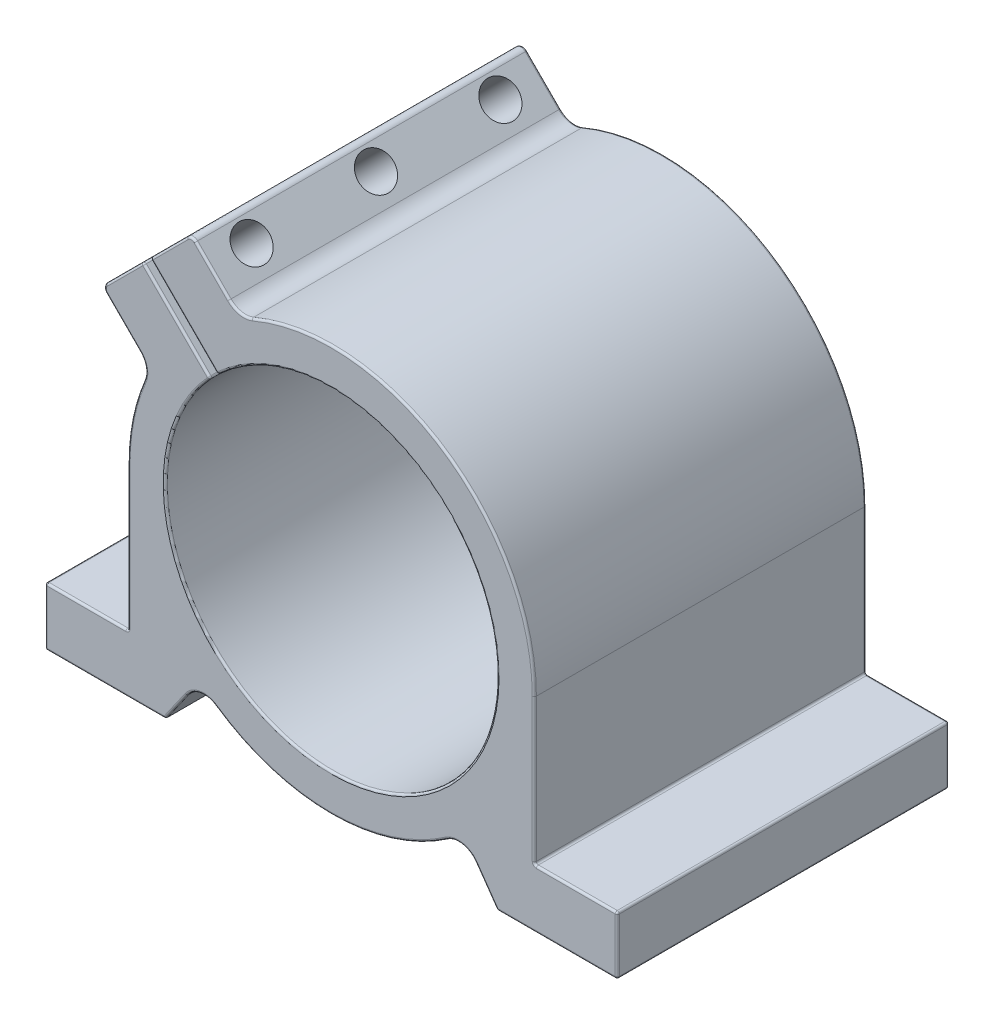
from build123d import *

# Parameters (mm, degrees)
EXTRUDE_1_DEPTH     = 40
FILLET_1_R          = 5
SKETCH_2_R          = 4.25
CUT_EXTRUDE_1_DEPTH = 16.5
SKETCH_3_R          = 3.1
CUT_EXTRUDE_2_DEPTH = 80
FILLET_2_R          = 1.5
FILLET_3_R          = 0.5


with BuildPart() as part:
    # Эскиз1 → Бобышка-Вытянуть1 (new body, symmetric)
    with BuildSketch(Plane.XY):
        with BuildLine():
            Line((-69, -49), (-40, -49))
            Line((-40, -49), (-31.795747001, -37.283112433))
            ThreePointArc((-31.795747001, -37.283112433), (-44.491525053, -20.530567417), (-49, 0))
            Line((-49, 0), (-49, -35))
            Line((-49, -35), (-69, -35))
            Line((-69, -35), (-69, -49))
        make_face()
        with BuildLine():
            ThreePointArc((-31.795747001, -37.283112433), (-16.942955681, -45.977562493), (-1.13e-07, -49))
            ThreePointArc((-1.13e-07, -49), (16.942955575, -45.977562532), (31.795747001, -37.283112433))
            ThreePointArc((31.795747001, -37.283112433), (44.491525053, -20.530567417), (49, 0))
            ThreePointArc((49, 0), (25.650917751, 41.749615789), (-22.144098715, 43.710855541))
            Line((-22.144098715, 43.710855541), (-15.364637764, 36.93139459))
            ThreePointArc((-15.364637764, 36.93139459), (22.197009815, 33.276008704), (40, 0))
            ThreePointArc((40, 0), (-7.834035243, -39.225347568), (-36.93139459, 15.364637764))
            Line((-36.93139459, 15.364637764), (-43.710855541, 22.144098715))
            ThreePointArc((-43.710855541, 22.144098715), (-47.659374322, 11.38349855), (-49, 0))
            ThreePointArc((-49, 0), (-44.491525053, -20.530567417), (-31.795747001, -37.283112433))
        make_face()
        with BuildLine():
            Line((40, -49), (69, -49))
            Line((69, -49), (69, -35))
            Line((69, -35), (49, -35))
            Line((49, -35), (49, 0))
            ThreePointArc((49, 0), (44.491525053, -20.530567417), (31.795747001, -37.283112433))
            Line((31.795747001, -37.283112433), (40, -49))
        make_face()
        with BuildLine():
            Line((-55.317291575, 33.750534749), (-43.710855541, 22.144098715))
            ThreePointArc((-43.710855541, 22.144098715), (-40.038824422, 28.246991679), (-35.520839896, 33.753072943))
            Line((-35.520839896, 33.753072943), (-45.417796639, 43.650029686))
            Line((-45.417796639, 43.650029686), (-55.317291575, 33.750534749))
        make_face()
        with BuildLine():
            ThreePointArc((-33.753072943, 35.520839896), (-28.246991679, 40.038824422), (-22.144098715, 43.710855541))
            Line((-22.144098715, 43.710855541), (-33.750534749, 55.317291575))
            Line((-33.750534749, 55.317291575), (-43.650029686, 45.417796639))
            Line((-43.650029686, 45.417796639), (-33.753072943, 35.520839896))
        make_face()
        with BuildLine():
            ThreePointArc((-35.520839896, 33.753072943), (-40.038824422, 28.246991679), (-43.710855541, 22.144098715))
            Line((-43.710855541, 22.144098715), (-36.93139459, 15.364637764))
            ThreePointArc((-36.93139459, 15.364637764), (-33.585157991, 21.726416242), (-29.154340671, 27.386573718))
            Line((-29.154340671, 27.386573718), (-35.520839896, 33.753072943))
        make_face()
        with BuildLine():
            Line((-15.364637764, 36.93139459), (-22.144098715, 43.710855541))
            ThreePointArc((-22.144098715, 43.710855541), (-28.246991679, 40.038824422), (-33.753072943, 35.520839896))
            Line((-33.753072943, 35.520839896), (-27.386573718, 29.154340671))
            ThreePointArc((-27.386573718, 29.154340671), (-21.726416242, 33.585157991), (-15.364637764, 36.93139459))
        make_face()
    extrude(amount=EXTRUDE_1_DEPTH, both=True)

    # Скругление1
    fillet_1_edges = [part.edges().sort_by_distance(p)[0] for p in [
        (-22.144098715, 43.710855541, 0),
        (31.795747001, -37.283112433, 0),
        (-31.795747001, -37.283112433, 0),
        (-43.710855541, 22.144098715, 0),
    ]]
    fillet(fillet_1_edges, radius=FILLET_1_R)

    # Эскиз2 → Вырез-Вытянуть1 (cut)
    with BuildSketch(Plane(origin=(10.783378413, 10.783378413, 0), x_dir=(0, 0, -1), z_dir=(0.707106781, 0.707106781, 0))):
        with Locations((-30, 56.519901884)):
            Circle(SKETCH_2_R)
        with Locations((0, 56.519901884)):
            Circle(SKETCH_2_R)
        with Locations((30, 56.519901884)):
            Circle(SKETCH_2_R)
    extrude(amount=-CUT_EXTRUDE_1_DEPTH, mode=Mode.SUBTRACT)

    # Эскиз3 → Вырез-Вытянуть2 (cut)
    with BuildSketch(Plane(origin=(-0.883883476, -0.883883476, 0), x_dir=(0, 0, -1), z_dir=(0.707106781, 0.707106781, 0))):
        with Locations((-30, 56.519901884)):
            Circle(SKETCH_3_R)
        with Locations((0, 56.519901884)):
            Circle(SKETCH_3_R)
        with Locations((30, 56.519901884)):
            Circle(SKETCH_3_R)
    extrude(amount=-CUT_EXTRUDE_2_DEPTH, mode=Mode.SUBTRACT)

    # Скругление2
    fillet_2_edges = [part.edges().sort_by_distance(p)[0] for p in [
        (-33.750534749, 55.317291575, 0),
        (-55.317291575, 33.750534749, 0),
    ]]
    fillet(fillet_2_edges, radius=FILLET_2_R)

    # Скругление3
    fillet_3_edges = [part.edges().sort_by_distance(p)[0] for p in [
        (-50.218654221, 28.651897395, -40),
        (-50.218654221, 28.651897395, 40),
        (-28.651897395, 50.218654221, -40),
        (-33.750534749, 54.695971232, -40),
        (-54.695971232, 33.750534749, -40),
        (-28.651897395, 50.218654221, 40),
        (-33.750534749, 54.695971232, 40),
        (-54.695971232, 33.750534749, 40),
        (-37.286068655, 35.518301702, 40),
        (-39.230612303, 49.837214021, -40),
        (-49.837214021, 39.230612303, 40),
        (27.053581004, 40.854666255, -40),
        (49, -17.5, -40),
        (59, -35, -40),
        (69, -42, -40),
        (54.5, -49, -40),
        (37.395225146, -45.279995984, -40),
        (-37.395225146, -45.279995984, -40),
        (-54.5, -49, -40),
        (-69, -42, -40),
        (-59, -35, -40),
        (-49, -17.5, -40),
        (-49.837214021, 39.230612303, -40),
        (-37.286068655, 35.518301702, -40),
        (28.284271247, -28.284271247, -40),
        (-35.518301702, 37.286068655, -40),
        (-49, -17.5, 40),
        (-59, -35, 40),
        (-43.650029686, 45.417796639, 0),
        (49, -35, 0),
        (69, -35, 0),
        (69, -49, 0),
        (40, -49, 0),
        (-40, -49, 0),
        (-69, -49, 0),
        (-69, -35, 0),
        (-49, -35, 0),
        (-45.417796639, 43.650029686, 0),
        (-29.154340671, 27.386573718, 0),
        (-27.386573718, 29.154340671, 0),
        (-35.518301702, 37.286068655, 40),
        (-69, -42, 40),
        (-54.5, -49, 40),
        (-37.395225146, -45.279995984, 40),
        (37.395225146, -45.279995984, 40),
        (54.5, -49, 40),
        (0, -49, -40),
        (0, -49, 40),
        (69, -42, 40),
        (-48.018382136, 9.758840969, -40),
        (-48.018382136, 9.758840969, 40),
        (59, -35, 40),
        (31.578390224, -39.506586306, -40),
        (31.578390224, -39.506586306, 40),
        (49, -17.5, 40),
        (-31.578390224, -39.506586306, -40),
        (-31.578390224, -39.506586306, 40),
        (-44.808277557, 22.033472619, -40),
        (-44.808277557, 22.033472619, 40),
        (27.053581004, 40.854666255, 40),
        (-22.033472619, 44.808277557, -40),
        (-22.033472619, 44.808277557, 40),
        (-39.230612303, 49.837214021, 40),
        (28.284271247, -28.284271247, 40),
    ]]
    fillet(fillet_3_edges, radius=FILLET_3_R)


solid = part.part
